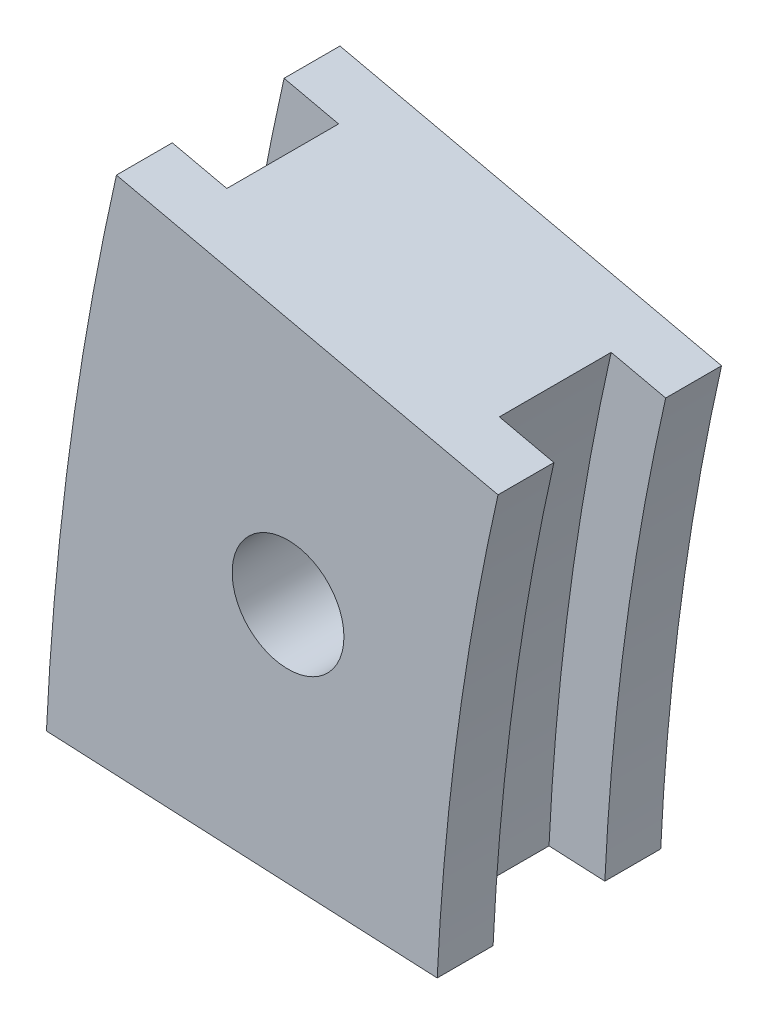
from build123d import *

# Parameters (mm, degrees)
EXTRUDE_1_DEPTH          = 4
CUT_EXTRUDE_1_DEPTH      = 2
CUT_EXTRUDE_1_DEPTH_BACK = 2
CUT_EXTRUDE_2_DEPTH      = 9


with BuildPart() as part:
    # 草图1 → 凸台-拉伸1 (new body, symmetric)
    with BuildSketch(Plane.XY):
        with BuildLine():
            Line((-92.895446795, 4.408623913), (-106.879707603, 5.072287728))
            ThreePointArc((-106.879707603, 5.072287728), (-106.030919043, 14.368166442), (-104.375171166, 23.554694734))
            Line((-104.375171166, 23.554694734), (-90.718606715, 20.472772059))
            ThreePointArc((-90.718606715, 20.472772059), (-92.157714682, 12.488219431), (-92.895446795, 4.408623913))
        make_face()
    extrude(amount=EXTRUDE_1_DEPTH, both=True)

    # 草图2 → 切除-拉伸1 (cut, two sides)
    with BuildSketch(Plane.XY) as cut_extrude_1_sk:
        with BuildLine():
            Line((-104.881956059, 4.977478611), (-106.879707603, 5.072287728))
            ThreePointArc((-106.879707603, 5.072287728), (-106.030919043, 14.368166442), (-104.375171166, 23.554694734))
            Line((-104.375171166, 23.554694734), (-102.424233387, 23.114420066))
            ThreePointArc((-102.424233387, 23.114420066), (-104.049032706, 14.099602583), (-104.881956059, 4.977478611))
        make_face()
        with BuildLine():
            Line((-80.070774139, 18.069839991), (-92.669544493, 20.913046727))
            ThreePointArc((-92.669544493, 20.913046727), (-94.139601019, 12.75678329), (-94.893198339, 4.503433029))
            Line((-94.893198339, 4.503433029), (-81.992113947, 3.891174505))
            ThreePointArc((-81.992113947, 3.891174505), (-81.340970995, 11.022451002), (-80.070774139, 18.069839991))
        make_face()
    extrude(amount=CUT_EXTRUDE_1_DEPTH, mode=Mode.SUBTRACT)
    extrude(cut_extrude_1_sk.sketch, amount=-CUT_EXTRUDE_1_DEPTH_BACK, mode=Mode.SUBTRACT)

    # 草图3 → 切除-拉伸2 (cut, through all)
    with BuildSketch(Plane.XY.offset(4)):
        with BuildLine():
            ThreePointArc((-96.785643699, 14.691278047), (-97.964954769, 15.293433182), (-99.261988484, 15.026845581))
            Line((-99.261988484, 15.026845581), (-98.233518627, 13.311546845))
            Line((-98.233518627, 13.311546845), (-96.785643699, 14.691278047))
        make_face()
        with BuildLine():
            Line((-98.233518627, 13.311546845), (-99.261988484, 15.026845581))
            ThreePointArc((-99.261988484, 15.026845581), (-100.215404965, 13.580110704), (-99.681393556, 11.931815643))
            Line((-99.681393556, 11.931815643), (-98.233518627, 13.311546845))
        make_face()
        with BuildLine():
            Line((-96.785643699, 14.691278047), (-98.233518627, 13.311546845))
            Line((-98.233518627, 13.311546845), (-97.205048771, 11.596248109))
            ThreePointArc((-97.205048771, 11.596248109), (-96.493268687, 12.325884558), (-96.233518627, 13.311546845))
            ThreePointArc((-96.233518627, 13.311546845), (-96.376673203, 14.054598035), (-96.785643699, 14.691278047))
        make_face()
        with BuildLine():
            Line((-97.205048771, 11.596248109), (-98.233518627, 13.311546845))
            Line((-98.233518627, 13.311546845), (-99.681393556, 11.931815643))
            ThreePointArc((-99.681393556, 11.931815643), (-98.502082486, 11.329660508), (-97.205048771, 11.596248109))
        make_face()
    extrude(amount=-CUT_EXTRUDE_2_DEPTH, mode=Mode.SUBTRACT)


solid = part.part
